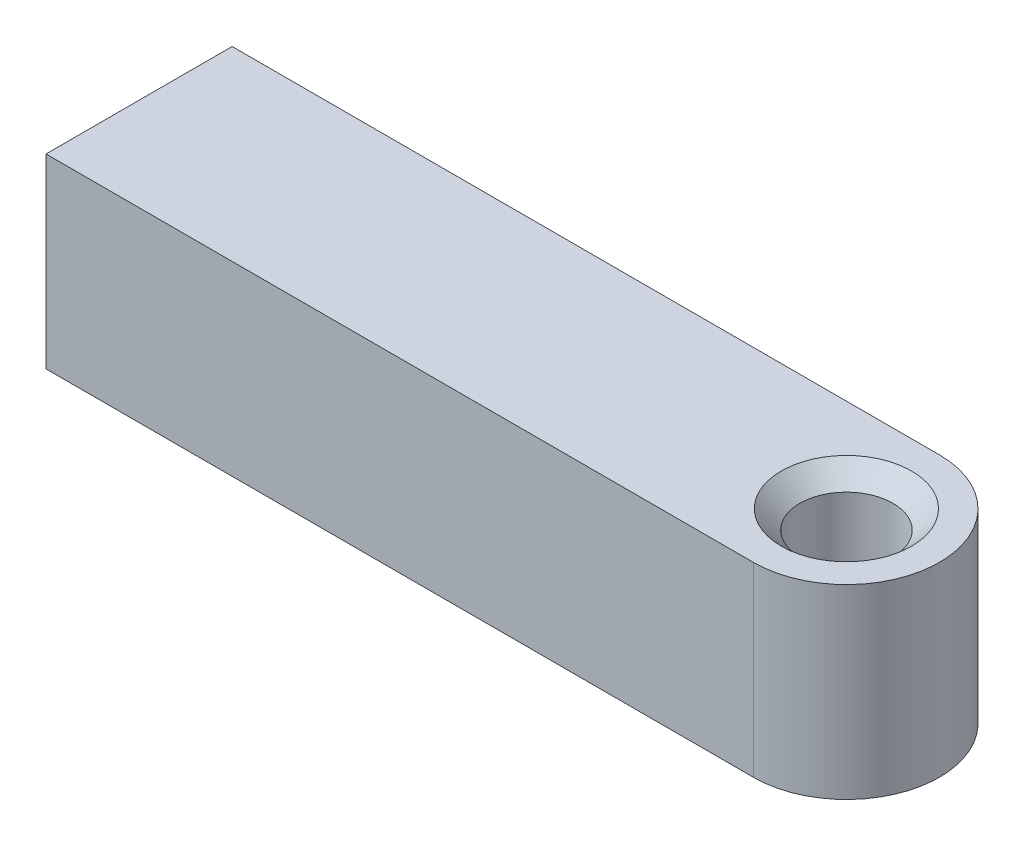
from build123d import *

# Parameters (mm, degrees)
BOSS_EXTRU_1_DEPTH = 10


with BuildPart() as part:
    # Esquisse1 → Boss.-Extru.1 (new body)
    with BuildSketch(Plane(origin=(0, 0, 0), x_dir=(1, 0, 0), z_dir=(0, 1, 0))):
        with BuildLine():
            Line((0, 5), (-38, 5))
            Line((-38, 5), (-38, -5))
            Line((-38, -5), (0, -5))
            ThreePointArc((0, -5), (5, 0), (0, 5))
        make_face()
    extrude(amount=BOSS_EXTRU_1_DEPTH)

    # Esquisse3 → Trou taraudé M61 (revolve, cut)
    with BuildSketch(Plane(origin=(0, 10, 0), x_dir=(0, 0, 1), z_dir=(1, 0, 0))):
        Polygon((0, 0), (0, 10), (3.5, 10), (2.5, 9), (2.5, 1), (3.5, 0), align=None)
    revolve(axis=Axis((0, 16.35, 0), (0, -1, 0)), mode=Mode.SUBTRACT)


solid = part.part
